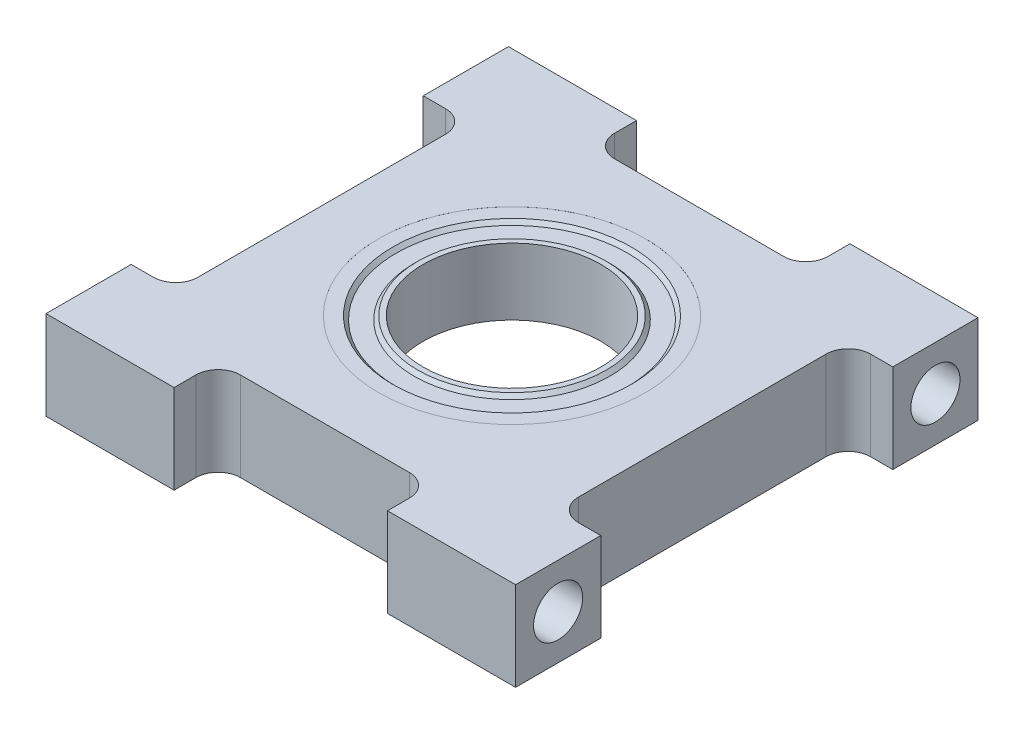
from build123d import *

# Parameters (mm, degrees)
SKETCH1_R                      = 8.89
BOSS_EXTRUDE1_DEPTH            = 6.35
SKETCH2_R                      = 9.525
CUT_EXTRUDE1_DEPTH             = 4.7625
SKETCH3_R                      = 9.525
SKETCH3_R_2                    = 8.255
BOSS_EXTRUDE2_DEPTH            = 4.75996
CHAMFER1_SIZE                  = 0.254
SKETCH4_R                      = 6.985
SKETCH4_R_2                    = 6.35
BOSS_EXTRUDE3_DEPTH            = 4.75996
CHAMFER2_SIZE                  = 0.254
SKETCH5_R                      = 8.255
SKETCH5_R_2                    = 6.985
BOSS_EXTRUDE4_DEPTH            = 4.2545
F_6_32_TAPPED_HOLE1_AT_2_COUNT = 2
F_6_32_TAPPED_HOLE1_AT_2_PITCH = 26.940768363


with BuildPart() as part:
    # Sketch1 → Boss-Extrude1 (new body)
    with BuildSketch(Plane(origin=(0, 0, 0), x_dir=(1, 0, 0), z_dir=(0, 1, 0))):
        with BuildLine():
            Line((-16.764, -16.51), (-7.62, -16.51))
            Line((-7.62, -16.51), (-7.62, -14.9479))
            ThreePointArc((-7.62, -14.9479), (-7.155032015, -13.825367985), (-6.0325, -13.3604))
            Line((-6.0325, -13.3604), (6.0325, -13.3604))
            ThreePointArc((6.0325, -13.3604), (7.155032015, -13.825367985), (7.62, -14.9479))
            Line((7.62, -14.9479), (7.62, -16.51))
            Line((7.62, -16.51), (16.764, -16.51))
            Line((16.764, -16.51), (16.764, -10.4267))
            Line((16.764, -10.4267), (15.1765, -10.4267))
            ThreePointArc((15.1765, -10.4267), (14.053967985, -9.961732015), (13.589, -8.8392))
            Line((13.589, -8.8392), (13.589, 8.8392))
            ThreePointArc((13.589, 8.8392), (14.053967985, 9.961732015), (15.1765, 10.4267))
            Line((15.1765, 10.4267), (16.764, 10.4267))
            Line((16.764, 10.4267), (16.764, 16.51))
            Line((16.764, 16.51), (7.62, 16.51))
            Line((7.62, 16.51), (7.62, 14.9479))
            ThreePointArc((7.62, 14.9479), (7.155032015, 13.825367985), (6.0325, 13.3604))
            Line((6.0325, 13.3604), (-6.0325, 13.3604))
            ThreePointArc((-6.0325, 13.3604), (-7.155032015, 13.825367985), (-7.62, 14.9479))
            Line((-7.62, 14.9479), (-7.62, 16.51))
            Line((-7.62, 16.51), (-16.764, 16.51))
            Line((-16.764, 16.51), (-16.764, 10.4267))
            Line((-16.764, 10.4267), (-15.1765, 10.4267))
            ThreePointArc((-15.1765, 10.4267), (-14.053967985, 9.961732015), (-13.589, 8.8392))
            Line((-13.589, 8.8392), (-13.589, -8.8392))
            ThreePointArc((-13.589, -8.8392), (-14.053967985, -9.961732015), (-15.1765, -10.4267))
            Line((-15.1765, -10.4267), (-16.764, -10.4267))
            Line((-16.764, -10.4267), (-16.764, -16.51))
        make_face()
        Circle(SKETCH1_R, mode=Mode.SUBTRACT)
    extrude(amount=BOSS_EXTRUDE1_DEPTH)

    # Sketch2 → Cut-Extrude1 (cut)
    with BuildSketch(Plane(origin=(0, 6.35, 0), x_dir=(1, 0, 0), z_dir=(0, 1, 0))):
        Circle(SKETCH2_R)
    extrude(amount=-CUT_EXTRUDE1_DEPTH, mode=Mode.SUBTRACT)

    # Sketch3 → Boss-Extrude2 (add)
    with BuildSketch(Plane(origin=(0, 1.5875, 0), x_dir=(-1, 0, 0), z_dir=(0, 1, 0))):
        Circle(SKETCH3_R)
        Circle(SKETCH3_R_2, mode=Mode.SUBTRACT)
    extrude(amount=BOSS_EXTRUDE2_DEPTH)

    # Chamfer1
    chamfer1_edges = [part.edges().sort_by_distance(p)[0] for p in [
        (8.255, 1.5875, 0),
        (8.255, 6.34746, 0),
    ]]
    chamfer(chamfer1_edges, length=CHAMFER1_SIZE)



with BuildPart() as body_2:
    # Sketch4 → Boss-Extrude3 (new body)
    with BuildSketch(Plane(origin=(0, 1.5875, 0), x_dir=(-1, 0, 0), z_dir=(0, 1, 0))):
        Circle(SKETCH4_R)
        Circle(SKETCH4_R_2, mode=Mode.SUBTRACT)
    extrude(amount=BOSS_EXTRUDE3_DEPTH)

    # Chamfer2
    chamfer2_edges = [body_2.edges().sort_by_distance(p)[0] for p in [
        (6.985, 1.5875, 0),
        (6.985, 6.34746, 0),
    ]]
    chamfer(chamfer2_edges, length=CHAMFER2_SIZE)


with BuildPart() as part_1:
    add(part.part)

    add(body_2.part)  # Boss-Extrude4 merges body 2
    # Sketch5 → Boss-Extrude4 (add)
    with BuildSketch(Plane(origin=(0, 6.09346, 0), x_dir=(-1, 0, 0), z_dir=(0, 1, 0))):
        Circle(SKETCH5_R)
        Circle(SKETCH5_R_2, mode=Mode.SUBTRACT)
    extrude(amount=-BOSS_EXTRUDE4_DEPTH)

    # Sketch8 → #6-32 Tapped Hole1 (revolve, cut)
    with BuildSketch(Plane(origin=(-16.764, 3.175, -13.470384182), x_dir=(0, 0, 1), z_dir=(0, 1, 0))):
        Polygon((0, 0), (0, 8.76289403), (1.35255, 7.9502), (1.35255, 7.0104), (1.7526, 7.0104), (1.7526, 0), align=None)
    f_6_32_tapped_hole1 = revolve(axis=Axis((-23.114, 3.175, -13.470384182), (1, 0, 0)), mode=Mode.SUBTRACT)

    # #6-32 Tapped Hole1 at 2: #6-32 Tapped Hole1 ×2
    with Locations(*[(0, 0, i * F_6_32_TAPPED_HOLE1_AT_2_PITCH) for i in range(1, F_6_32_TAPPED_HOLE1_AT_2_COUNT)]):
        add(f_6_32_tapped_hole1, mode=Mode.SUBTRACT)

    # Mirror1: #6-32 Tapped Hole1 across plane
    add(f_6_32_tapped_hole1.mirror(Plane(origin=(0, 0, 0), x_dir=(0, 0, 1), z_dir=(1, 0, 0))), mode=Mode.SUBTRACT)

    # Mirror1 copy 1 sketch → Mirror1 copy 1 (revolve, cut)
    with BuildSketch(Plane(origin=(16.764, 3.175, 13.470384182), x_dir=(0, 0, 1), z_dir=(0, 1, 0))):
        Polygon((0, 0), (0, -8.76289403), (1.35255, -7.9502), (1.35255, -7.0104), (1.7526, -7.0104), (1.7526, 0), align=None)
    revolve(axis=Axis((23.114, 3.175, 13.470384182), (1, 0, 0)), mode=Mode.SUBTRACT)


solid = part_1.part
